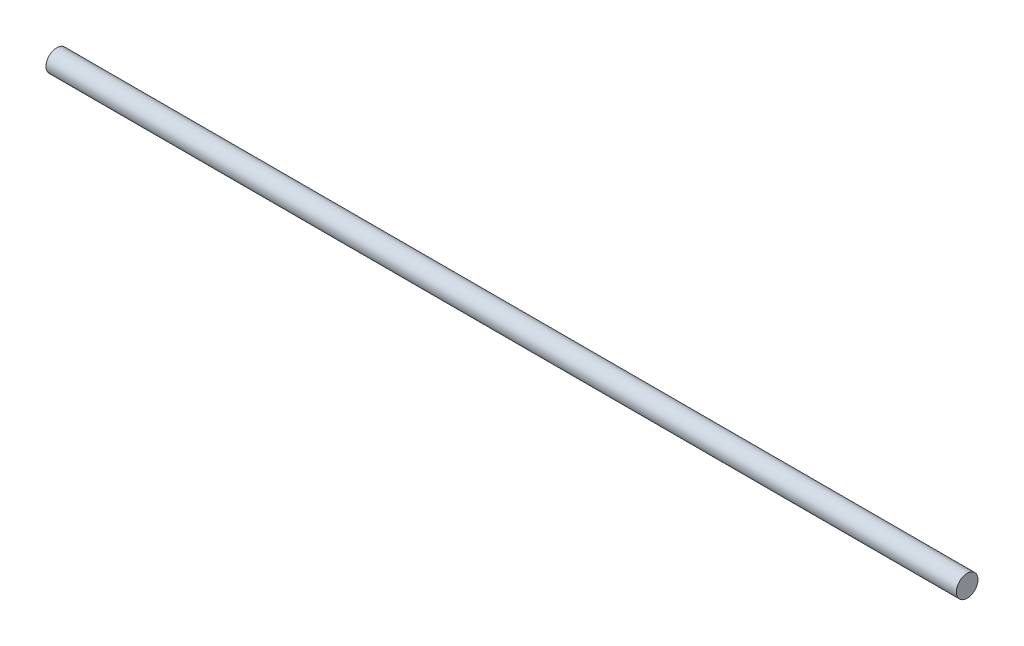
from build123d import *

# Parameters (mm, degrees)
SKETCH1_W = 126
SKETCH1_H = 1.5


with BuildPart() as part:
    # Sketch1 → Revolve1 (revolve)
    with BuildSketch(Plane.XY):
        Rectangle(SKETCH1_W, SKETCH1_H)
    revolve(axis=Axis((-63, -0.75, 0), (1, 0, 0)))


solid = part.part
